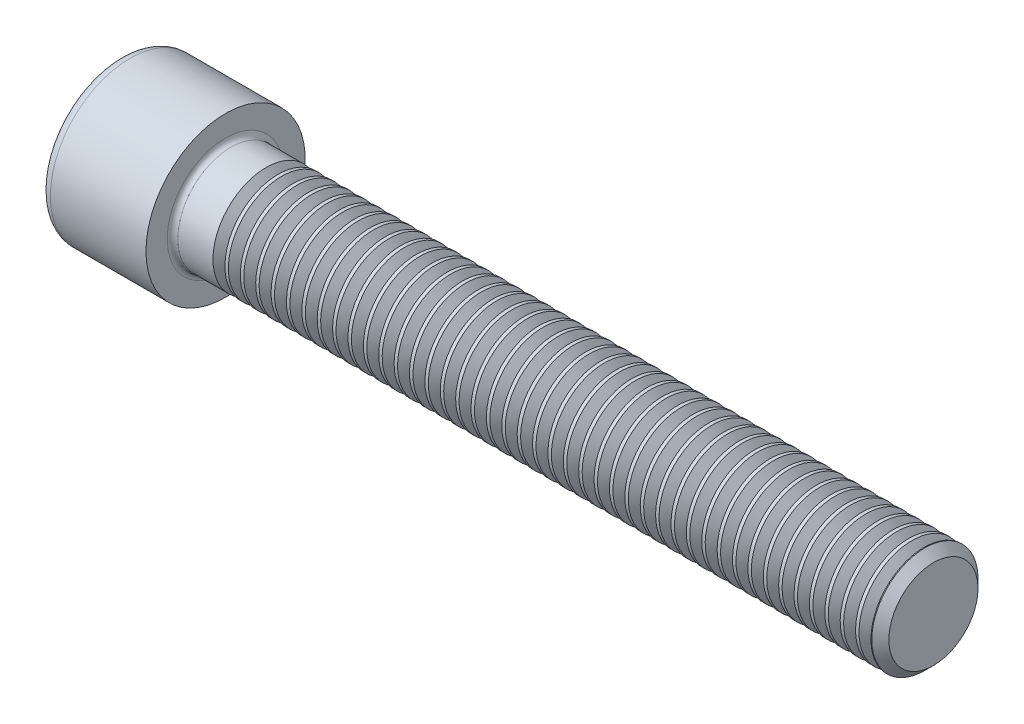
from build123d import *

# Parameters (mm, degrees)
FILLET1_R       = 0.6
FILLET2_R       = 1.2
HEX_2_DEPTH     = 6
THDSCHPAT_COUNT = 43
THDSCHPAT_PITCH = 1.738372093


with BuildPart() as part:
    # BodySke → Base-Revolve (revolve)
    with BuildSketch(Plane.XY, mode=Mode.PRIVATE) as base_revolve_sk:
        Polygon((0, 0), (0, 9), (12, 9), (12, 6), (91.036, 6), (92, 5.036), (92, 0), align=None)
    revolve(base_revolve_sk.sketch.rotate(Axis((-31.75, 0, 0), (1, 0, 0)), 90), axis=Axis((-31.75, 0, 0), (1, 0, 0)))  # turned: the seam where the file's is

    # Fillet1
    fillet1_edges = [part.edges().sort_by_distance(p)[0] for p in [
        (12, 0, -6),
    ]]
    fillet(fillet1_edges, radius=FILLET1_R)

    # Fillet2
    fillet2_edges = [part.edges().sort_by_distance(p)[0] for p in [
        (0, 0, -9),
    ]]
    fillet(fillet2_edges, radius=FILLET2_R)

    # Sketch2 → Hex-PreBroach (revolve, cut)
    with BuildSketch(Plane.XY, mode=Mode.PRIVATE) as hex_prebroach_sk:
        Polygon((0, 5.0125), (6, 5.0125), (8.893968224, 0), (0, 0), align=None)
    revolve(hex_prebroach_sk.sketch.rotate(Axis((0, 0, 0), (1, 0, 0)), 90), axis=Axis((0, 0, 0), (1, 0, 0)), mode=Mode.SUBTRACT)  # turned: the seam where the file's is

    # Sketch3 → Hex 2 (cut)
    with BuildSketch(Plane(origin=(0, 0, 0), x_dir=(0, 0.5, 0.866025404), z_dir=(-1, 0, 0))):
        Polygon((2.893968224, 5.0125), (-2.893968224, 5.0125), (-5.787936449, 0), (-2.893968224, -5.0125), (2.893968224, -5.0125), (5.787936449, 0), align=None)
    extrude(amount=-HEX_2_DEPTH, mode=Mode.SUBTRACT)

    # ThdSchSke → ThreadSchematic (revolve, cut)
    with BuildSketch(Plane.XY, mode=Mode.PRIVATE) as threadschematic_sk:
        Polygon((17.25, -5.036), (16.574999933, -6), (16.574999933, -7.5), (17.925000067, -7.5), (17.925000067, -6), align=None)
    threadschematic = revolve(threadschematic_sk.sketch.rotate(Axis((-3.175, 0, 0), (1, 0, 0)), 270), axis=Axis((-3.175, 0, 0), (1, 0, 0)), mode=Mode.SUBTRACT)  # turned: the seam where the file's is

    # ThdSchPat: ThreadSchematic ×43
    with Locations(*[(i * THDSCHPAT_PITCH, 0, 0) for i in range(1, THDSCHPAT_COUNT)]):
        add(threadschematic, mode=Mode.SUBTRACT)


solid = part.part
